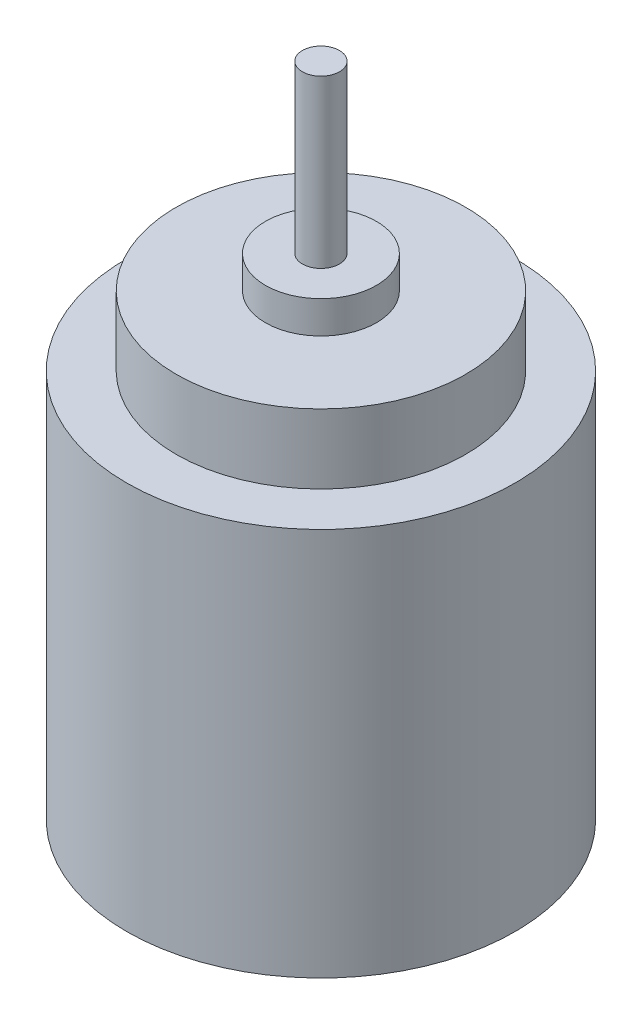
from build123d import *

# Parameters (mm, degrees)
SKETCH1_R           = 10.5
BOSS_EXTRUDE1_DEPTH = 21
SKETCH2_R           = 7.825
BOSS_EXTRUDE2_DEPTH = 3.75
SKETCH3_R           = 3
BOSS_EXTRUDE3_DEPTH = 1.75
SKETCH4_R           = 1
BOSS_EXTRUDE4_DEPTH = 9


with BuildPart() as part:
    # Sketch1 → Boss-Extrude1 (new body)
    with BuildSketch(Plane(origin=(0, 0, 0), x_dir=(1, 0, 0), z_dir=(0, 1, 0))):
        Circle(SKETCH1_R)
    extrude(amount=BOSS_EXTRUDE1_DEPTH)

    # Sketch2 → Boss-Extrude2 (add)
    with BuildSketch(Plane(origin=(0, 21, 0), x_dir=(1, 0, 0), z_dir=(0, 1, 0))):
        Circle(SKETCH2_R)
    extrude(amount=BOSS_EXTRUDE2_DEPTH)

    # Sketch3 → Boss-Extrude3 (add)
    with BuildSketch(Plane(origin=(0, 24.75, 0), x_dir=(1, 0, 0), z_dir=(0, 1, 0))):
        Circle(SKETCH3_R)
    extrude(amount=BOSS_EXTRUDE3_DEPTH)

    # Sketch4 → Boss-Extrude4 (add)
    with BuildSketch(Plane(origin=(0, 26.5, 0), x_dir=(1, 0, 0), z_dir=(0, 1, 0))):
        Circle(SKETCH4_R)
    extrude(amount=BOSS_EXTRUDE4_DEPTH)


solid = part.part
